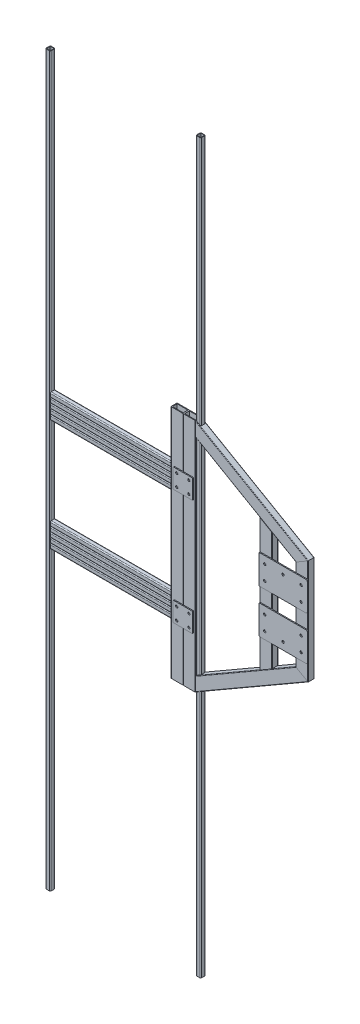
from build123d import *

# Parameters (mm, degrees)
TUBE_SQUARE_20_X_20_X_2_0_13_DEPTH    = 3000
TUBE_SQUARE_20_X_20_X_2_0_13_2_DEPTH  = 3000
TUBE_SQUARE_20_X_20_X_2_0_14_DEPTH    = 600
TUBE_SQUARE_20_X_20_X_2_0_14_2_DEPTH  = 600
TUBE_SQUARE_20_X_20_X_2_0_14_3_DEPTH  = 600
TUBE_SQUARE_20_X_20_X_2_0_14_4_DEPTH  = 600
TUBE_SQUARE_20_X_20_X_2_0_14_5_DEPTH  = 600
TUBE_SQUARE_20_X_20_X_2_0_14_6_DEPTH  = 600
TUBE_SQUARE_20_X_20_X_2_0_14_7_DEPTH  = 600
TUBE_SQUARE_20_X_20_X_2_0_14_8_DEPTH  = 600
TUBE_SQUARE_20_X_20_X_2_0_14_9_DEPTH  = 600
TUBE_SQUARE_20_X_20_X_2_0_14_10_DEPTH = 600
SKETCH112_W                           = 44.8
SKETCH112_H                           = 19.4
TUBE_RECTANGULAR_RECT_15_DEPTH        = 403.478768497
SKETCH112_ON_SEGMENT_2_W              = 44.8
SKETCH112_ON_SEGMENT_2_H              = 19.4
TUBE_RECTANGULAR_RECT_15_2_DEPTH      = 575.436671447
SKETCH112_ON_SEGMENT_3_W              = 44.8
SKETCH112_ON_SEGMENT_3_H              = 19.4
TUBE_RECTANGULAR_RECT_15_3_DEPTH      = 970
SKETCH112_ON_SEGMENT_4_W              = 44.8
SKETCH112_ON_SEGMENT_4_H              = 19.4
TUBE_RECTANGULAR_RECT_15_4_DEPTH      = 970
SKETCH113_W                           = 44.8
SKETCH113_H                           = 19.4
TUBE_RECTANGULAR_RECT_16_DEPTH        = 535.694109834
SKETCH114_W                           = 44.8
SKETCH114_H                           = 19.4
TUBE_RECTANGULAR_RECT_17_DEPTH        = 535.694109834
BODY_13_RUN_ON_DEPTH                  = 282.511752
BODY_START                            = 535.694109937
BODY_18_RUN_ON_DEPTH                  = 223.73643
BODY_START_2                          = -3e-09
BODY_17_RUN_ON_DEPTH                  = 231.068778
BODY_START_3                          = 403.478768497
BODY_13_RUN_ON_2_DEPTH                = 282.511752
SKETCH116_W                           = 199.999986833
SKETCH116_H                           = 120
SKETCH116_R                           = 5
BOSS_EXTRUDE1_DEPTH                   = 4
BOSS_EXTRUDE1_2_DEPTH                 = 4
BOSS_EXTRUDE1_3_DEPTH                 = 4
SKETCH116_W_2                         = 199.999987092
BOSS_EXTRUDE1_4_DEPTH                 = 4
FILLET1_R                             = 5
FILLET2_R                             = 5


with BuildPart() as part:
    # Sketch15 → Tube (square) 20 X 20 X 2.0(13) (new body)
    with BuildSketch(Plane(origin=(-10, -1232.284106073, 0), x_dir=(-1, 0, 0), z_dir=(0, 1, 0))):
        with BuildLine():
            Line((-6, -10), (6, -10))
            ThreePointArc((6, -10), (8.828427125, -8.828427125), (10, -6))
            Line((10, -6), (10, 6))
            ThreePointArc((10, 6), (8.828427125, 8.828427125), (6, 10))
            Line((6, 10), (-6, 10))
            ThreePointArc((-6, 10), (-8.828427125, 8.828427125), (-10, 6))
            Line((-10, 6), (-10, -6))
            ThreePointArc((-10, -6), (-8.828427125, -8.828427125), (-6, -10))
        make_face()
        with BuildLine():
            Line((-6, -8), (6, -8))
            ThreePointArc((6, -8), (7.414213562, -7.414213562), (8, -6))
            Line((8, -6), (8, 6))
            ThreePointArc((8, 6), (7.414213562, 7.414213562), (6, 8))
            Line((6, 8), (-6, 8))
            ThreePointArc((-6, 8), (-7.414213562, 7.414213562), (-8, 6))
            Line((-8, 6), (-8, -6))
            ThreePointArc((-8, -6), (-7.414213562, -7.414213562), (-6, -8))
        make_face(mode=Mode.SUBTRACT)
    extrude(amount=TUBE_SQUARE_20_X_20_X_2_0_13_DEPTH)


with BuildPart() as body_2:
    # Sketch15 on segment 2 (carried to segment 2) → Tube _square_ 20 X 20 X 2.0_13 2 (new body)
    with BuildSketch(Plane(origin=(610, -1232.284106073, 0), x_dir=(-1, 0, 0), z_dir=(0, 1, 0))):
        with BuildLine():
            Line((-6, -10), (6, -10))
            ThreePointArc((6, -10), (8.828427125, -8.828427125), (10, -6))
            Line((10, -6), (10, 6))
            ThreePointArc((10, 6), (8.828427125, 8.828427125), (6, 10))
            Line((6, 10), (-6, 10))
            ThreePointArc((-6, 10), (-8.828427125, 8.828427125), (-10, 6))
            Line((-10, 6), (-10, -6))
            ThreePointArc((-10, -6), (-8.828427125, -8.828427125), (-6, -10))
        make_face()
        with BuildLine():
            Line((-6, -8), (6, -8))
            ThreePointArc((6, -8), (7.414213562, -7.414213562), (8, -6))
            Line((8, -6), (8, 6))
            ThreePointArc((8, 6), (7.414213562, 7.414213562), (6, 8))
            Line((6, 8), (-6, 8))
            ThreePointArc((-6, 8), (-7.414213562, 7.414213562), (-8, 6))
            Line((-8, 6), (-8, -6))
            ThreePointArc((-8, -6), (-7.414213562, -7.414213562), (-6, -8))
        make_face(mode=Mode.SUBTRACT)
    extrude(amount=TUBE_SQUARE_20_X_20_X_2_0_13_2_DEPTH)


with BuildPart() as body_3:
    # Sketch16 → Tube (square) 20 X 20 X 2.0(14) (new body)
    with BuildSketch(Plane.YZ):
        with BuildLine():
            Line((-6, -10), (6, -10))
            ThreePointArc((6, -10), (8.828427125, -8.828427125), (10, -6))
            Line((10, -6), (10, 6))
            ThreePointArc((10, 6), (8.828427125, 8.828427125), (6, 10))
            Line((6, 10), (-6, 10))
            ThreePointArc((-6, 10), (-8.828427125, 8.828427125), (-10, 6))
            Line((-10, 6), (-10, -6))
            ThreePointArc((-10, -6), (-8.828427125, -8.828427125), (-6, -10))
        make_face()
        with BuildLine():
            Line((-6, -8), (6, -8))
            ThreePointArc((6, -8), (7.414213562, -7.414213562), (8, -6))
            Line((8, -6), (8, 6))
            ThreePointArc((8, 6), (7.414213562, 7.414213562), (6, 8))
            Line((6, 8), (-6, 8))
            ThreePointArc((-6, 8), (-7.414213562, 7.414213562), (-8, 6))
            Line((-8, 6), (-8, -6))
            ThreePointArc((-8, -6), (-7.414213562, -7.414213562), (-6, -8))
        make_face(mode=Mode.SUBTRACT)
    extrude(amount=TUBE_SQUARE_20_X_20_X_2_0_14_DEPTH)


with BuildPart() as body_4:
    # Sketch16 on segment 2 (carried to segment 2) → Tube _square_ 20 X 20 X 2.0_14 2 (new body)
    with BuildSketch(Plane(origin=(0, 20, 0), x_dir=(0, 1, 0), z_dir=(1, 0, 0))):
        with BuildLine():
            Line((-6, -10), (6, -10))
            ThreePointArc((6, -10), (8.828427125, -8.828427125), (10, -6))
            Line((10, -6), (10, 6))
            ThreePointArc((10, 6), (8.828427125, 8.828427125), (6, 10))
            Line((6, 10), (-6, 10))
            ThreePointArc((-6, 10), (-8.828427125, 8.828427125), (-10, 6))
            Line((-10, 6), (-10, -6))
            ThreePointArc((-10, -6), (-8.828427125, -8.828427125), (-6, -10))
        make_face()
        with BuildLine():
            Line((-6, -8), (6, -8))
            ThreePointArc((6, -8), (7.414213562, -7.414213562), (8, -6))
            Line((8, -6), (8, 6))
            ThreePointArc((8, 6), (7.414213562, 7.414213562), (6, 8))
            Line((6, 8), (-6, 8))
            ThreePointArc((-6, 8), (-7.414213562, 7.414213562), (-8, 6))
            Line((-8, 6), (-8, -6))
            ThreePointArc((-8, -6), (-7.414213562, -7.414213562), (-6, -8))
        make_face(mode=Mode.SUBTRACT)
    extrude(amount=TUBE_SQUARE_20_X_20_X_2_0_14_2_DEPTH)


with BuildPart() as body_5:
    # Sketch16 on segment 3 (carried to segment 3) → Tube _square_ 20 X 20 X 2.0_14 3 (new body)
    with BuildSketch(Plane(origin=(0, 40, 0), x_dir=(0, 1, 0), z_dir=(1, 0, 0))):
        with BuildLine():
            Line((-6, -10), (6, -10))
            ThreePointArc((6, -10), (8.828427125, -8.828427125), (10, -6))
            Line((10, -6), (10, 6))
            ThreePointArc((10, 6), (8.828427125, 8.828427125), (6, 10))
            Line((6, 10), (-6, 10))
            ThreePointArc((-6, 10), (-8.828427125, 8.828427125), (-10, 6))
            Line((-10, 6), (-10, -6))
            ThreePointArc((-10, -6), (-8.828427125, -8.828427125), (-6, -10))
        make_face()
        with BuildLine():
            Line((-6, -8), (6, -8))
            ThreePointArc((6, -8), (7.414213562, -7.414213562), (8, -6))
            Line((8, -6), (8, 6))
            ThreePointArc((8, 6), (7.414213562, 7.414213562), (6, 8))
            Line((6, 8), (-6, 8))
            ThreePointArc((-6, 8), (-7.414213562, 7.414213562), (-8, 6))
            Line((-8, 6), (-8, -6))
            ThreePointArc((-8, -6), (-7.414213562, -7.414213562), (-6, -8))
        make_face(mode=Mode.SUBTRACT)
    extrude(amount=TUBE_SQUARE_20_X_20_X_2_0_14_3_DEPTH)


with BuildPart() as body_6:
    # Sketch16 on segment 4 (carried to segment 4) → Tube _square_ 20 X 20 X 2.0_14 4 (new body)
    with BuildSketch(Plane(origin=(0, 60, 0), x_dir=(0, 1, 0), z_dir=(1, 0, 0))):
        with BuildLine():
            Line((-6, -10), (6, -10))
            ThreePointArc((6, -10), (8.828427125, -8.828427125), (10, -6))
            Line((10, -6), (10, 6))
            ThreePointArc((10, 6), (8.828427125, 8.828427125), (6, 10))
            Line((6, 10), (-6, 10))
            ThreePointArc((-6, 10), (-8.828427125, 8.828427125), (-10, 6))
            Line((-10, 6), (-10, -6))
            ThreePointArc((-10, -6), (-8.828427125, -8.828427125), (-6, -10))
        make_face()
        with BuildLine():
            Line((-6, -8), (6, -8))
            ThreePointArc((6, -8), (7.414213562, -7.414213562), (8, -6))
            Line((8, -6), (8, 6))
            ThreePointArc((8, 6), (7.414213562, 7.414213562), (6, 8))
            Line((6, 8), (-6, 8))
            ThreePointArc((-6, 8), (-7.414213562, 7.414213562), (-8, 6))
            Line((-8, 6), (-8, -6))
            ThreePointArc((-8, -6), (-7.414213562, -7.414213562), (-6, -8))
        make_face(mode=Mode.SUBTRACT)
    extrude(amount=TUBE_SQUARE_20_X_20_X_2_0_14_4_DEPTH)


with BuildPart() as body_7:
    # Sketch16 on segment 5 (carried to segment 5) → Tube _square_ 20 X 20 X 2.0_14 5 (new body)
    with BuildSketch(Plane(origin=(0, 80, 0), x_dir=(0, 1, 0), z_dir=(1, 0, 0))):
        with BuildLine():
            Line((-6, -10), (6, -10))
            ThreePointArc((6, -10), (8.828427125, -8.828427125), (10, -6))
            Line((10, -6), (10, 6))
            ThreePointArc((10, 6), (8.828427125, 8.828427125), (6, 10))
            Line((6, 10), (-6, 10))
            ThreePointArc((-6, 10), (-8.828427125, 8.828427125), (-10, 6))
            Line((-10, 6), (-10, -6))
            ThreePointArc((-10, -6), (-8.828427125, -8.828427125), (-6, -10))
        make_face()
        with BuildLine():
            Line((-6, -8), (6, -8))
            ThreePointArc((6, -8), (7.414213562, -7.414213562), (8, -6))
            Line((8, -6), (8, 6))
            ThreePointArc((8, 6), (7.414213562, 7.414213562), (6, 8))
            Line((6, 8), (-6, 8))
            ThreePointArc((-6, 8), (-7.414213562, 7.414213562), (-8, 6))
            Line((-8, 6), (-8, -6))
            ThreePointArc((-8, -6), (-7.414213562, -7.414213562), (-6, -8))
        make_face(mode=Mode.SUBTRACT)
    extrude(amount=TUBE_SQUARE_20_X_20_X_2_0_14_5_DEPTH)


with BuildPart() as body_8:
    # Sketch16 on segment 6 (carried to segment 6) → Tube _square_ 20 X 20 X 2.0_14 6 (new body)
    with BuildSketch(Plane(origin=(0, 460, 0), x_dir=(0, 1, 0), z_dir=(1, 0, 0))):
        with BuildLine():
            Line((-6, -10), (6, -10))
            ThreePointArc((6, -10), (8.828427125, -8.828427125), (10, -6))
            Line((10, -6), (10, 6))
            ThreePointArc((10, 6), (8.828427125, 8.828427125), (6, 10))
            Line((6, 10), (-6, 10))
            ThreePointArc((-6, 10), (-8.828427125, 8.828427125), (-10, 6))
            Line((-10, 6), (-10, -6))
            ThreePointArc((-10, -6), (-8.828427125, -8.828427125), (-6, -10))
        make_face()
        with BuildLine():
            Line((-6, -8), (6, -8))
            ThreePointArc((6, -8), (7.414213562, -7.414213562), (8, -6))
            Line((8, -6), (8, 6))
            ThreePointArc((8, 6), (7.414213562, 7.414213562), (6, 8))
            Line((6, 8), (-6, 8))
            ThreePointArc((-6, 8), (-7.414213562, 7.414213562), (-8, 6))
            Line((-8, 6), (-8, -6))
            ThreePointArc((-8, -6), (-7.414213562, -7.414213562), (-6, -8))
        make_face(mode=Mode.SUBTRACT)
    extrude(amount=TUBE_SQUARE_20_X_20_X_2_0_14_6_DEPTH)


with BuildPart() as body_9:
    # Sketch16 on segment 7 (carried to segment 7) → Tube _square_ 20 X 20 X 2.0_14 7 (new body)
    with BuildSketch(Plane(origin=(0, 480, 0), x_dir=(0, 1, 0), z_dir=(1, 0, 0))):
        with BuildLine():
            Line((-6, -10), (6, -10))
            ThreePointArc((6, -10), (8.828427125, -8.828427125), (10, -6))
            Line((10, -6), (10, 6))
            ThreePointArc((10, 6), (8.828427125, 8.828427125), (6, 10))
            Line((6, 10), (-6, 10))
            ThreePointArc((-6, 10), (-8.828427125, 8.828427125), (-10, 6))
            Line((-10, 6), (-10, -6))
            ThreePointArc((-10, -6), (-8.828427125, -8.828427125), (-6, -10))
        make_face()
        with BuildLine():
            Line((-6, -8), (6, -8))
            ThreePointArc((6, -8), (7.414213562, -7.414213562), (8, -6))
            Line((8, -6), (8, 6))
            ThreePointArc((8, 6), (7.414213562, 7.414213562), (6, 8))
            Line((6, 8), (-6, 8))
            ThreePointArc((-6, 8), (-7.414213562, 7.414213562), (-8, 6))
            Line((-8, 6), (-8, -6))
            ThreePointArc((-8, -6), (-7.414213562, -7.414213562), (-6, -8))
        make_face(mode=Mode.SUBTRACT)
    extrude(amount=TUBE_SQUARE_20_X_20_X_2_0_14_7_DEPTH)


with BuildPart() as body_10:
    # Sketch16 on segment 8 (carried to segment 8) → Tube _square_ 20 X 20 X 2.0_14 8 (new body)
    with BuildSketch(Plane(origin=(0, 500, 0), x_dir=(0, 1, 0), z_dir=(1, 0, 0))):
        with BuildLine():
            Line((-6, -10), (6, -10))
            ThreePointArc((6, -10), (8.828427125, -8.828427125), (10, -6))
            Line((10, -6), (10, 6))
            ThreePointArc((10, 6), (8.828427125, 8.828427125), (6, 10))
            Line((6, 10), (-6, 10))
            ThreePointArc((-6, 10), (-8.828427125, 8.828427125), (-10, 6))
            Line((-10, 6), (-10, -6))
            ThreePointArc((-10, -6), (-8.828427125, -8.828427125), (-6, -10))
        make_face()
        with BuildLine():
            Line((-6, -8), (6, -8))
            ThreePointArc((6, -8), (7.414213562, -7.414213562), (8, -6))
            Line((8, -6), (8, 6))
            ThreePointArc((8, 6), (7.414213562, 7.414213562), (6, 8))
            Line((6, 8), (-6, 8))
            ThreePointArc((-6, 8), (-7.414213562, 7.414213562), (-8, 6))
            Line((-8, 6), (-8, -6))
            ThreePointArc((-8, -6), (-7.414213562, -7.414213562), (-6, -8))
        make_face(mode=Mode.SUBTRACT)
    extrude(amount=TUBE_SQUARE_20_X_20_X_2_0_14_8_DEPTH)


with BuildPart() as body_11:
    # Sketch16 on segment 9 (carried to segment 9) → Tube _square_ 20 X 20 X 2.0_14 9 (new body)
    with BuildSketch(Plane(origin=(0, 520, 0), x_dir=(0, 1, 0), z_dir=(1, 0, 0))):
        with BuildLine():
            Line((-6, -10), (6, -10))
            ThreePointArc((6, -10), (8.828427125, -8.828427125), (10, -6))
            Line((10, -6), (10, 6))
            ThreePointArc((10, 6), (8.828427125, 8.828427125), (6, 10))
            Line((6, 10), (-6, 10))
            ThreePointArc((-6, 10), (-8.828427125, 8.828427125), (-10, 6))
            Line((-10, 6), (-10, -6))
            ThreePointArc((-10, -6), (-8.828427125, -8.828427125), (-6, -10))
        make_face()
        with BuildLine():
            Line((-6, -8), (6, -8))
            ThreePointArc((6, -8), (7.414213562, -7.414213562), (8, -6))
            Line((8, -6), (8, 6))
            ThreePointArc((8, 6), (7.414213562, 7.414213562), (6, 8))
            Line((6, 8), (-6, 8))
            ThreePointArc((-6, 8), (-7.414213562, 7.414213562), (-8, 6))
            Line((-8, 6), (-8, -6))
            ThreePointArc((-8, -6), (-7.414213562, -7.414213562), (-6, -8))
        make_face(mode=Mode.SUBTRACT)
    extrude(amount=TUBE_SQUARE_20_X_20_X_2_0_14_9_DEPTH)


with BuildPart() as body_12:
    # Sketch16 on segment 10 (carried to segment 10) → Tube _square_ 20 X 20 X 2.0_14 10 (new body)
    with BuildSketch(Plane(origin=(0, 540, 0), x_dir=(0, 1, 0), z_dir=(1, 0, 0))):
        with BuildLine():
            Line((-6, -10), (6, -10))
            ThreePointArc((6, -10), (8.828427125, -8.828427125), (10, -6))
            Line((10, -6), (10, 6))
            ThreePointArc((10, 6), (8.828427125, 8.828427125), (6, 10))
            Line((6, 10), (-6, 10))
            ThreePointArc((-6, 10), (-8.828427125, 8.828427125), (-10, 6))
            Line((-10, 6), (-10, -6))
            ThreePointArc((-10, -6), (-8.828427125, -8.828427125), (-6, -10))
        make_face()
        with BuildLine():
            Line((-6, -8), (6, -8))
            ThreePointArc((6, -8), (7.414213562, -7.414213562), (8, -6))
            Line((8, -6), (8, 6))
            ThreePointArc((8, 6), (7.414213562, 7.414213562), (6, 8))
            Line((6, 8), (-6, 8))
            ThreePointArc((-6, 8), (-7.414213562, 7.414213562), (-8, 6))
            Line((-8, 6), (-8, -6))
            ThreePointArc((-8, -6), (-7.414213562, -7.414213562), (-6, -8))
        make_face(mode=Mode.SUBTRACT)
    extrude(amount=TUBE_SQUARE_20_X_20_X_2_0_14_10_DEPTH)


with BuildPart() as body_13:
    # Sketch112 → Tube (rectangular) RECT(15) (new body)
    with BuildSketch(Plane(origin=(1040, 63.958595333, 0), x_dir=(-1, 0, 0), z_dir=(0, 1, 0))):
        with BuildLine():
            Line((23.4, 12.7), (-23.4, 12.7))
            ThreePointArc((-23.4, 12.7), (-24.814213562, 12.114213562), (-25.4, 10.7))
            Line((-25.4, 10.7), (-25.4, -10.7))
            ThreePointArc((-25.4, -10.7), (-24.814213562, -12.114213562), (-23.4, -12.7))
            Line((-23.4, -12.7), (23.4, -12.7))
            ThreePointArc((23.4, -12.7), (24.814213562, -12.114213562), (25.4, -10.7))
            Line((25.4, -10.7), (25.4, 10.7))
            ThreePointArc((25.4, 10.7), (24.814213562, 12.114213562), (23.4, 12.7))
        make_face()
        Rectangle(SKETCH112_W, SKETCH112_H, mode=Mode.SUBTRACT)
    extrude(amount=TUBE_RECTANGULAR_RECT_15_DEPTH)

    # Sketch112 → body 13 run on (add)
    with BuildSketch(Plane(origin=(1040, 63.958595333, 0), x_dir=(-1, 0, 0), z_dir=(0, 1, 0))):
        with BuildLine():
            Line((23.4, 12.7), (-23.4, 12.7))
            ThreePointArc((-23.4, 12.7), (-24.814213562, 12.114213562), (-25.4, 10.7))
            Line((-25.4, 10.7), (-25.4, -10.7))
            ThreePointArc((-25.4, -10.7), (-24.814213562, -12.114213562), (-23.4, -12.7))
            Line((-23.4, -12.7), (23.4, -12.7))
            ThreePointArc((23.4, -12.7), (24.814213562, -12.114213562), (25.4, -10.7))
            Line((25.4, -10.7), (25.4, 10.7))
            ThreePointArc((25.4, 10.7), (24.814213562, 12.114213562), (23.4, 12.7))
        make_face()
        Rectangle(SKETCH112_W, SKETCH112_H, mode=Mode.SUBTRACT)
    extrude(amount=-BODY_13_RUN_ON_DEPTH)

    # Trim/Extend5
    split(bisect_by=Plane(origin=(1040, 63.958595333, 0), x_dir=(-0.866025404, 0.5, 0), z_dir=(0.5, 0.866025404, 0)), keep=Keep.TOP)

    # Sketch112 → body 13 run on 2 (add)
    with BuildSketch(Plane(origin=(1040, 63.958595333, 0), x_dir=(-1, 0, 0), z_dir=(0, 1, 0)).offset(BODY_START_3)):
        with BuildLine():
            Line((23.4, 12.7), (-23.4, 12.7))
            ThreePointArc((-23.4, 12.7), (-24.814213562, 12.114213562), (-25.4, 10.7))
            Line((-25.4, 10.7), (-25.4, -10.7))
            ThreePointArc((-25.4, -10.7), (-24.814213562, -12.114213562), (-23.4, -12.7))
            Line((-23.4, -12.7), (23.4, -12.7))
            ThreePointArc((23.4, -12.7), (24.814213562, -12.114213562), (25.4, -10.7))
            Line((25.4, -10.7), (25.4, 10.7))
            ThreePointArc((25.4, 10.7), (24.814213562, 12.114213562), (23.4, 12.7))
        make_face()
        Rectangle(SKETCH112_W, SKETCH112_H, mode=Mode.SUBTRACT)
    extrude(amount=BODY_13_RUN_ON_2_DEPTH)

    # Trim/Extend6
    split(bisect_by=Plane(origin=(1040, 467.43736383, 0), x_dir=(0.866025404, 0.5, 0), z_dir=(0.5, -0.866025404, 0)), keep=Keep.TOP)


with BuildPart() as body_14:
    # Sketch112 on segment 2 (carried to segment 2) → Tube _rectangular_ RECT_15 2 (new body)
    with BuildSketch(Plane(origin=(891.080087664, -22.020356142, 0), x_dir=(-1, 0, 0), z_dir=(0, 1, 0))):
        with BuildLine():
            Line((23.4, 12.7), (-23.4, 12.7))
            ThreePointArc((-23.4, 12.7), (-24.814213562, 12.114213562), (-25.4, 10.7))
            Line((-25.4, 10.7), (-25.4, -10.7))
            ThreePointArc((-25.4, -10.7), (-24.814213562, -12.114213562), (-23.4, -12.7))
            Line((-23.4, -12.7), (23.4, -12.7))
            ThreePointArc((23.4, -12.7), (24.814213562, -12.114213562), (25.4, -10.7))
            Line((25.4, -10.7), (25.4, 10.7))
            ThreePointArc((25.4, 10.7), (24.814213562, 12.114213562), (23.4, 12.7))
        make_face()
        Rectangle(SKETCH112_ON_SEGMENT_2_W, SKETCH112_ON_SEGMENT_2_H, mode=Mode.SUBTRACT)
    extrude(amount=TUBE_RECTANGULAR_RECT_15_2_DEPTH)

    # Trim_Extend9 13
    split(bisect_by=Plane(origin=(808.037646112, 572.031497615, 0), x_dir=(0.866025404, -0.5, 0), z_dir=(-0.5, -0.866025404, 0)), keep=Keep.TOP)

    # Trim_Extend9 50
    split(bisect_by=Plane(origin=(808.037646111, -40.635538451, 0), x_dir=(-0.866025404, -0.5, 0), z_dir=(-0.5, 0.866025404, 0)), keep=Keep.TOP)


with BuildPart() as body_15:
    # Sketch112 on segment 3 (carried to segment 3) → Tube _rectangular_ RECT_15 3 (new body)
    with BuildSketch(Plane(origin=(576.075292226, -219.302020418, 0), x_dir=(-1, 0, 0), z_dir=(0, 1, 0))):
        with BuildLine():
            Line((23.4, 12.7), (-23.4, 12.7))
            ThreePointArc((-23.4, 12.7), (-24.814213562, 12.114213562), (-25.4, 10.7))
            Line((-25.4, 10.7), (-25.4, -10.7))
            ThreePointArc((-25.4, -10.7), (-24.814213562, -12.114213562), (-23.4, -12.7))
            Line((-23.4, -12.7), (23.4, -12.7))
            ThreePointArc((23.4, -12.7), (24.814213562, -12.114213562), (25.4, -10.7))
            Line((25.4, -10.7), (25.4, 10.7))
            ThreePointArc((25.4, 10.7), (24.814213562, 12.114213562), (23.4, 12.7))
        make_face()
        Rectangle(SKETCH112_ON_SEGMENT_3_W, SKETCH112_ON_SEGMENT_3_H, mode=Mode.SUBTRACT)
    extrude(amount=TUBE_RECTANGULAR_RECT_15_3_DEPTH)


with BuildPart() as body_16:
    # Sketch112 on segment 4 (carried to segment 4) → Tube _rectangular_ RECT_15 4 (new body)
    with BuildSketch(Plane(origin=(525.275292226, -219.302020418, 0), x_dir=(-1, 0, 0), z_dir=(0, 1, 0))):
        with BuildLine():
            Line((23.4, 12.7), (-23.4, 12.7))
            ThreePointArc((-23.4, 12.7), (-24.814213562, 12.114213562), (-25.4, 10.7))
            Line((-25.4, 10.7), (-25.4, -10.7))
            ThreePointArc((-25.4, -10.7), (-24.814213562, -12.114213562), (-23.4, -12.7))
            Line((-23.4, -12.7), (23.4, -12.7))
            ThreePointArc((23.4, -12.7), (24.814213562, -12.114213562), (25.4, -10.7))
            Line((25.4, -10.7), (25.4, 10.7))
            ThreePointArc((25.4, 10.7), (24.814213562, 12.114213562), (23.4, 12.7))
        make_face()
        Rectangle(SKETCH112_ON_SEGMENT_4_W, SKETCH112_ON_SEGMENT_4_H, mode=Mode.SUBTRACT)
    extrude(amount=TUBE_RECTANGULAR_RECT_15_4_DEPTH)


with BuildPart() as body_17:
    # Sketch113 → Tube (rectangular) RECT(16) (new body)
    with BuildSketch(Plane(origin=(1040, 467.43736383, 0), x_dir=(-0.4999999999999974, -0.8660254037844402, 0), z_dir=(-0.8660254037844402, 0.4999999999999974, 0))):
        with BuildLine():
            Line((23.4, 12.7), (-23.4, 12.7))
            ThreePointArc((-23.4, 12.7), (-24.814213562, 12.114213562), (-25.4, 10.7))
            Line((-25.4, 10.7), (-25.4, -10.7))
            ThreePointArc((-25.4, -10.7), (-24.814213562, -12.114213562), (-23.4, -12.7))
            Line((-23.4, -12.7), (23.4, -12.7))
            ThreePointArc((23.4, -12.7), (24.814213562, -12.114213562), (25.4, -10.7))
            Line((25.4, -10.7), (25.4, 10.7))
            ThreePointArc((25.4, 10.7), (24.814213562, 12.114213562), (23.4, 12.7))
        make_face()
        Rectangle(SKETCH113_W, SKETCH113_H, mode=Mode.SUBTRACT)
    extrude(amount=TUBE_RECTANGULAR_RECT_16_DEPTH)

    # Trim_Extend2 9
    split(bisect_by=Plane(origin=(601.475292226, 265.697979582, 0), x_dir=(0, 1, 0), z_dir=(1, 0, 0)), keep=Keep.TOP)

    # Sketch113 → body 17 run on (add)
    with BuildSketch(Plane(origin=(1040, 467.43736383, 0), x_dir=(-0.4999999999999974, -0.8660254037844402, 0), z_dir=(-0.8660254037844402, 0.4999999999999974, 0)).offset(BODY_START_2)):
        with BuildLine():
            Line((23.4, 12.7), (-23.4, 12.7))
            ThreePointArc((-23.4, 12.7), (-24.814213562, 12.114213562), (-25.4, 10.7))
            Line((-25.4, 10.7), (-25.4, -10.7))
            ThreePointArc((-25.4, -10.7), (-24.814213562, -12.114213562), (-23.4, -12.7))
            Line((-23.4, -12.7), (23.4, -12.7))
            ThreePointArc((23.4, -12.7), (24.814213562, -12.114213562), (25.4, -10.7))
            Line((25.4, -10.7), (25.4, 10.7))
            ThreePointArc((25.4, 10.7), (24.814213562, 12.114213562), (23.4, 12.7))
        make_face()
        Rectangle(SKETCH113_W, SKETCH113_H, mode=Mode.SUBTRACT)
    extrude(amount=-BODY_17_RUN_ON_DEPTH)

    # Trim/Extend6
    split(bisect_by=Plane(origin=(1040, 467.43736383, 0), x_dir=(-0.866025404, -0.5, 0), z_dir=(-0.5, 0.866025404, 0)), keep=Keep.TOP)


with BuildPart() as body_18:
    # Sketch114 → Tube (rectangular) RECT(17) (new body)
    with BuildSketch(Plane(origin=(576.075292226, -203.888459584, 0), x_dir=(-0.49999999999999806, 0.8660254037844397, 0), z_dir=(0.8660254037844397, 0.49999999999999806, 0))):
        with BuildLine():
            Line((23.4, 12.7), (-23.4, 12.7))
            ThreePointArc((-23.4, 12.7), (-24.814213562, 12.114213562), (-25.4, 10.7))
            Line((-25.4, 10.7), (-25.4, -10.7))
            ThreePointArc((-25.4, -10.7), (-24.814213562, -12.114213562), (-23.4, -12.7))
            Line((-23.4, -12.7), (23.4, -12.7))
            ThreePointArc((23.4, -12.7), (24.814213562, -12.114213562), (25.4, -10.7))
            Line((25.4, -10.7), (25.4, 10.7))
            ThreePointArc((25.4, 10.7), (24.814213562, 12.114213562), (23.4, 12.7))
        make_face()
        Rectangle(SKETCH114_W, SKETCH114_H, mode=Mode.SUBTRACT)
    extrude(amount=TUBE_RECTANGULAR_RECT_17_DEPTH)

    # Trim_Extend1 9
    split(bisect_by=Plane(origin=(601.475292226, 265.697979582, 0), x_dir=(0, 1, 0), z_dir=(1, 0, 0)), keep=Keep.TOP)

    # Sketch114 → body 18 run on (add)
    with BuildSketch(Plane(origin=(576.075292226, -203.888459584, 0), x_dir=(-0.49999999999999806, 0.8660254037844397, 0), z_dir=(0.8660254037844397, 0.49999999999999806, 0)).offset(BODY_START)):
        with BuildLine():
            Line((23.4, 12.7), (-23.4, 12.7))
            ThreePointArc((-23.4, 12.7), (-24.814213562, 12.114213562), (-25.4, 10.7))
            Line((-25.4, 10.7), (-25.4, -10.7))
            ThreePointArc((-25.4, -10.7), (-24.814213562, -12.114213562), (-23.4, -12.7))
            Line((-23.4, -12.7), (23.4, -12.7))
            ThreePointArc((23.4, -12.7), (24.814213562, -12.114213562), (25.4, -10.7))
            Line((25.4, -10.7), (25.4, 10.7))
            ThreePointArc((25.4, 10.7), (24.814213562, 12.114213562), (23.4, 12.7))
        make_face()
        Rectangle(SKETCH114_W, SKETCH114_H, mode=Mode.SUBTRACT)
    extrude(amount=BODY_18_RUN_ON_DEPTH)

    # Trim/Extend5
    split(bisect_by=Plane(origin=(1040, 63.958595333, 0), x_dir=(0.866025404, -0.5, 0), z_dir=(-0.5, -0.866025404, 0)), keep=Keep.TOP)


with BuildPart() as body_19:
    # Sketch116 → Boss-Extrude1 (new body)
    with BuildSketch(Plane.XY.offset(12.7)):
        with Locations((966.080094248, 175.697979582)):
            Rectangle(SKETCH116_W, SKETCH116_H)
        with Locations((891.080087664, 205.697979582)):
            Circle(SKETCH116_R, mode=Mode.SUBTRACT)
        with Locations((1041.080087664, 205.697979582)):
            Circle(SKETCH116_R, mode=Mode.SUBTRACT)
        with Locations((891.080087664, 145.697979582)):
            Circle(SKETCH116_R, mode=Mode.SUBTRACT)
        with Locations((966.080087664, 145.697979582)):
            Circle(SKETCH116_R, mode=Mode.SUBTRACT)
        with Locations((1041.080087664, 145.697979582)):
            Circle(SKETCH116_R, mode=Mode.SUBTRACT)
    extrude(amount=BOSS_EXTRUDE1_DEPTH)

    # Fillet1
    fillet1_edges = [body_19.edges().sort_by_distance(p)[0] for p in [
        (866.080100831, 235.697979582, 14.7),
        (1066.080087664, 235.697979582, 14.7),
        (1066.080087664, 115.697979582, 14.7),
        (866.080100831, 115.697979582, 14.7),
    ]]
    fillet(fillet1_edges, radius=FILLET1_R)


with BuildPart() as body_20:
    # Sketch116 → Boss-Extrude1 2 (new body)
    with BuildSketch(Plane.XY.offset(12.7)):
        with BuildLine():
            Line((513.343959721, 65.96761883), (513.343959914, -10.03238117))
            ThreePointArc((513.343959914, -10.03238117), (513.929746356, -11.446594731), (515.343959919, -12.032381165))
            Line((515.343959919, -12.032381165), (591.343959919, -12.032380971))
            ThreePointArc((591.343959919, -12.032380971), (592.75817348, -11.44659453), (593.343959914, -10.032380966))
            Line((593.343959914, -10.032380966), (593.343959721, 65.967619034))
            ThreePointArc((593.343959721, 65.967619034), (592.758173279, 67.381832595), (591.343959716, 67.967619029))
            Line((591.343959716, 67.967619029), (515.343959716, 67.967618835))
            ThreePointArc((515.343959716, 67.967618835), (513.929746155, 67.381832394), (513.343959721, 65.96761883))
        make_face()
        with Locations((528.343959881, 2.967618869)):
            Circle(SKETCH116_R, mode=Mode.SUBTRACT)
        with Locations((578.343959881, 2.967618996)):
            Circle(SKETCH116_R, mode=Mode.SUBTRACT)
        with Locations((578.343959754, 52.967618996)):
            Circle(SKETCH116_R, mode=Mode.SUBTRACT)
        with Locations((528.343959754, 52.967618869)):
            Circle(SKETCH116_R, mode=Mode.SUBTRACT)
    extrude(amount=BOSS_EXTRUDE1_2_DEPTH)


with BuildPart() as body_21:
    # Sketch116 → Boss-Extrude1 3 (new body)
    with BuildSketch(Plane.XY.offset(12.7)):
        with BuildLine():
            Line((593.343958838, 465.955098288), (593.343958645, 541.955098288))
            ThreePointArc((593.343958645, 541.955098288), (592.758172203, 543.369311849), (591.34395864, 543.955098283))
            Line((591.34395864, 543.955098283), (515.34395864, 543.955098089))
            ThreePointArc((515.34395864, 543.955098089), (513.929745079, 543.369311648), (513.343958645, 541.955098084))
            Line((513.343958645, 541.955098084), (513.343958838, 465.955098084))
            ThreePointArc((513.343958838, 465.955098084), (513.92974528, 464.540884523), (515.343958843, 463.955098089))
            Line((515.343958843, 463.955098089), (591.343958843, 463.955098283))
            ThreePointArc((591.343958843, 463.955098283), (592.758172404, 464.540884724), (593.343958838, 465.955098288))
        make_face()
        with Locations((528.343958805, 478.955098122)):
            Circle(SKETCH116_R, mode=Mode.SUBTRACT)
        with Locations((578.343958805, 478.95509825)):
            Circle(SKETCH116_R, mode=Mode.SUBTRACT)
        with Locations((528.343958678, 528.955098122)):
            Circle(SKETCH116_R, mode=Mode.SUBTRACT)
        with Locations((578.343958678, 528.95509825)):
            Circle(SKETCH116_R, mode=Mode.SUBTRACT)
    extrude(amount=BOSS_EXTRUDE1_3_DEPTH)


with BuildPart() as body_22:
    # Sketch116 → Boss-Extrude1 4 (new body)
    with BuildSketch(Plane.XY.offset(12.7)):
        with Locations((966.080094118, 355.697979582)):
            Rectangle(SKETCH116_W_2, SKETCH116_H)
        with Locations((891.080087664, 325.697979582)):
            Circle(SKETCH116_R, mode=Mode.SUBTRACT)
        with Locations((891.080087664, 385.697979582)):
            Circle(SKETCH116_R, mode=Mode.SUBTRACT)
        with Locations((966.080087664, 385.697979582)):
            Circle(SKETCH116_R, mode=Mode.SUBTRACT)
        with Locations((1041.080087664, 325.697979582)):
            Circle(SKETCH116_R, mode=Mode.SUBTRACT)
        with Locations((1041.080087664, 385.697979582)):
            Circle(SKETCH116_R, mode=Mode.SUBTRACT)
    extrude(amount=BOSS_EXTRUDE1_4_DEPTH)

    # Fillet2
    fillet2_edges = [body_22.edges().sort_by_distance(p)[0] for p in [
        (866.080100572, 415.697979582, 14.7),
        (1066.080087664, 415.697979582, 14.7),
        (1066.080087664, 295.697979582, 14.7),
        (866.080100572, 295.697979582, 14.7),
    ]]
    fillet(fillet2_edges, radius=FILLET2_R)


solid = Compound([part.part, body_2.part, body_3.part, body_4.part, body_5.part, body_6.part, body_7.part, body_8.part, body_9.part, body_10.part, body_11.part, body_12.part, body_13.part, body_14.part, body_15.part, body_16.part, body_17.part, body_18.part, body_19.part, body_20.part, body_21.part, body_22.part])
